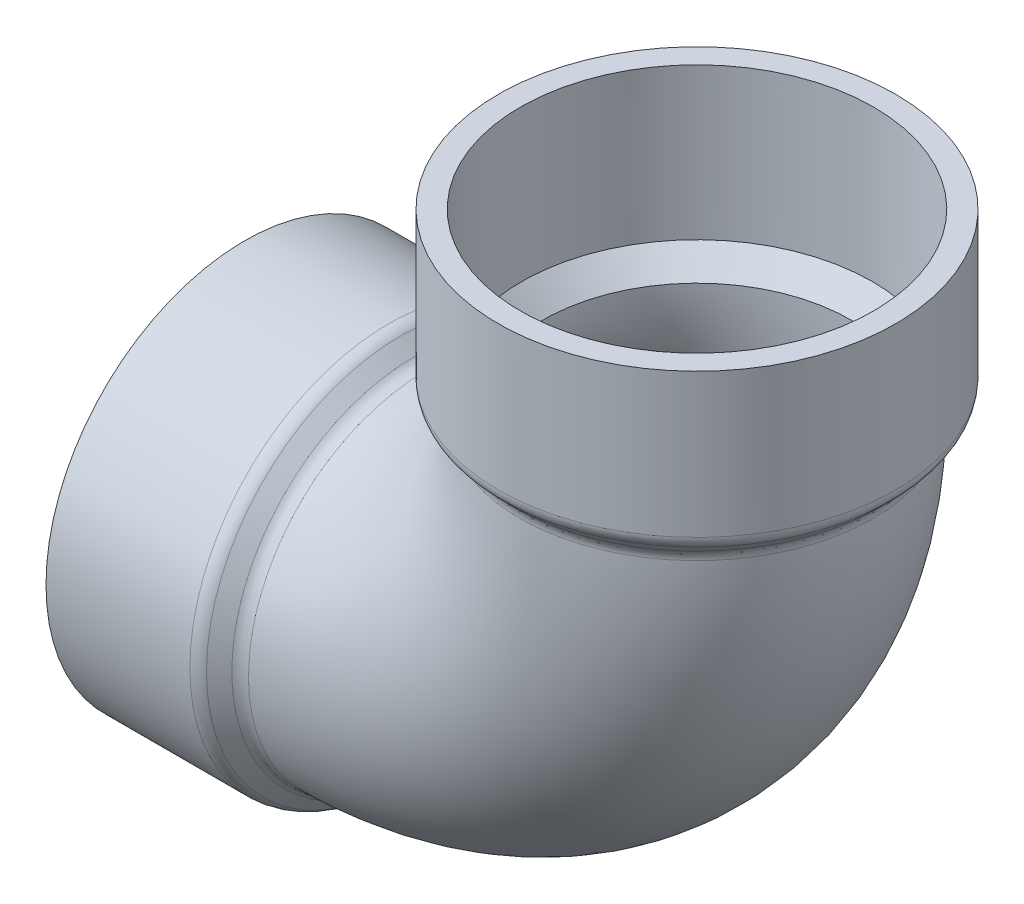
from build123d import *

# Parameters (mm, degrees)
SKETCH3_R   = 44.5516
SKETCH3_R_2 = 38.9636
FILLET1_R   = 4.191


with BuildPart() as part:
    # Sketch1 → Revolve1 (revolve)
    with BuildSketch(Plane.XY):
        Polygon((-76.2, -50.2285), (-70.5231, -44.5516), (-70.5231, -38.9636), (-76.2, -44.3865), (-114.3, -44.6405), (-114.3, -50.2285), align=None)
    revolve(axis=Axis((-114.3, 0, 0), (1, 0, 0)))



with BuildPart() as body_2:
    # Sketch2 → Revolve2 (revolve)
    with BuildSketch(Plane.XY):
        Polygon((44.6405, 114.3), (44.3865, 76.2), (38.9636, 70.5231), (44.5516, 70.5231), (50.2285, 76.2), (50.2285, 114.3), align=None)
    revolve(axis=Axis((0, 0, 0), (0, 1, 0)))


with BuildPart() as part_1:
    add(part.part)

    add(body_2.part)  # Sweep1 merges body 2
    # Sweep1: sweep along a path in Sketch4
    with BuildLine(Plane.XY) as sweep1_path:
        ThreePointArc((-70.5231, 0), (-20.65573776, 20.65573776), (0, 70.5231))
    # Sketch3 → Sweep1 (sweep)
    with BuildSketch(Plane(origin=(-70.5231, 0, 0), x_dir=(0, 0, -1), z_dir=(1, 0, 0))):
        Circle(SKETCH3_R)
        Circle(SKETCH3_R_2, mode=Mode.SUBTRACT)
    sweep(path=sweep1_path.line)

    # Fillet1
    fillet1_edges = [part_1.edges().sort_by_distance(p)[0] for p in [
        (-70.5231, 31.502738473, 31.502738473),
        (-31.502738473, 70.5231, 31.502738473),
        (-50.2285, 76.2, 0),
        (-76.2, 50.2285, 0),
    ]]
    fillet(fillet1_edges, radius=FILLET1_R)


solid = part_1.part
